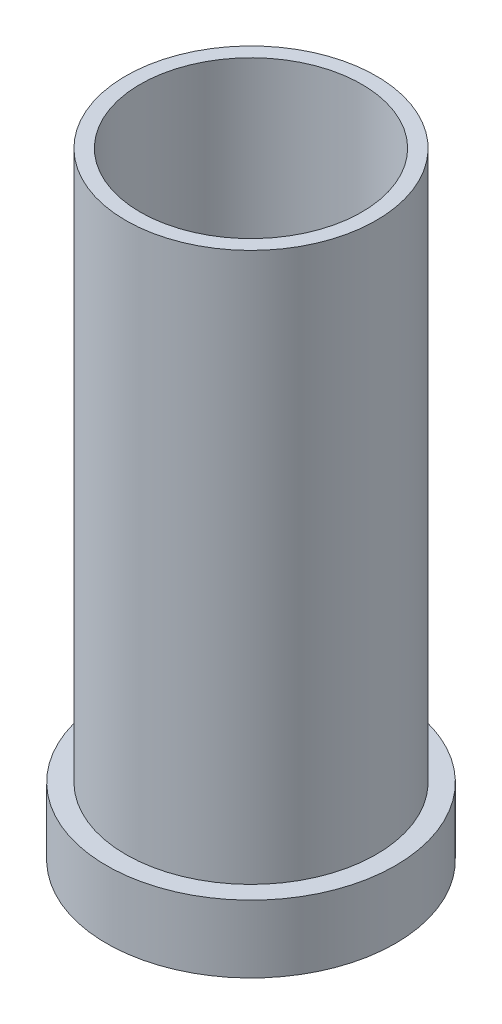
from build123d import *

# Parameters (mm, degrees)
SKETCH5_R                        = 7.5
SKETCH5_R_2                      = 5.5
EXTRUDE_THIN5_DEPTH              = 3.5
SKETCH6_R                        = 6.5
BOSS_EXTRUDE1_DEPTH              = 28.5
F_11_5_11_5_DIAMETER_HOLE1_D     = 11.5
F_11_5_11_5_DIAMETER_HOLE1_DEPTH = 18.5
F_11_5_11_5_DIAMETER_HOLE1_TIP   = 3.592998773
F_11_0_11_DIAMETER_HOLE2_D       = 11
F_11_0_11_DIAMETER_HOLE2_DEPTH   = 4
F_11_0_11_DIAMETER_HOLE2_TIP     = 3.436781436


with BuildPart() as part:
    # Sketch5 → Extrude-Thin5 (new body)
    with BuildSketch(Plane(origin=(0, 0, 0), x_dir=(1, 0, 0), z_dir=(0, 1, 0))):
        Circle(SKETCH5_R)
        Circle(SKETCH5_R_2, mode=Mode.SUBTRACT)
    extrude(amount=-EXTRUDE_THIN5_DEPTH)

    # Sketch6 → Boss-Extrude1 (add)
    with BuildSketch(Plane(origin=(0, 0, 0), x_dir=(1, 0, 0), z_dir=(0, 1, 0))):
        Circle(SKETCH6_R)
    extrude(amount=BOSS_EXTRUDE1_DEPTH)

    # Ø11.5 (11.5) Diameter Hole1
    with Locations(Plane.ZX.offset(28.5)):
        with Locations((0, 0)):
            Hole(F_11_5_11_5_DIAMETER_HOLE1_D / 2, depth=F_11_5_11_5_DIAMETER_HOLE1_DEPTH)
            with Locations((0, 0, -(F_11_5_11_5_DIAMETER_HOLE1_DEPTH + F_11_5_11_5_DIAMETER_HOLE1_TIP / 2))):  # 116° drill point
                Cone(0, F_11_5_11_5_DIAMETER_HOLE1_D / 2, F_11_5_11_5_DIAMETER_HOLE1_TIP, mode=Mode.SUBTRACT)

    # Ø11.0 (11) Diameter Hole2
    with Locations(Plane(origin=(0, -3.5, 0), x_dir=(0, 0, -1), z_dir=(0, -1, 0))):
        with Locations((0, 0)):
            Hole(F_11_0_11_DIAMETER_HOLE2_D / 2, depth=F_11_0_11_DIAMETER_HOLE2_DEPTH)
            with Locations((0, 0, -(F_11_0_11_DIAMETER_HOLE2_DEPTH + F_11_0_11_DIAMETER_HOLE2_TIP / 2))):  # 116° drill point
                Cone(0, F_11_0_11_DIAMETER_HOLE2_D / 2, F_11_0_11_DIAMETER_HOLE2_TIP, mode=Mode.SUBTRACT)


solid = part.part
